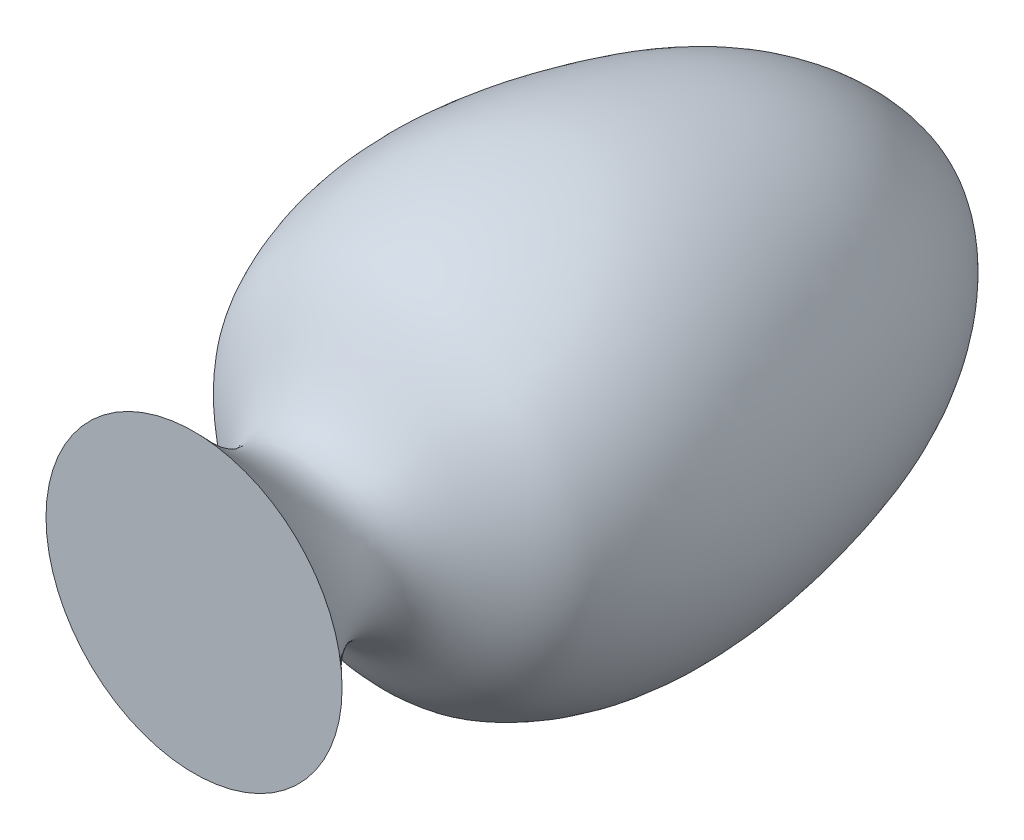
from build123d import *


with BuildPart() as part:
    # Sketch2 → Revolve4 (revolve)
    with BuildSketch(Plane(origin=(0, 0, 0), x_dir=(1, 0, 0), z_dir=(0, 1, 0))):
        with BuildLine():
            Line((200, -1000), (0, -1000))
            Line((0, -1000), (0, 0))
            add(Edge.make_bspline(
                [(0, 0), (101.557710259, -26.841383844), (214.347525711, -143.962732414), (294.480599989, -403.735703893), (311.598393321, -603.84806482), (198.797715862, -815.10136326), (-7.405534242, -810.839395017), (200, -1000)],
                knots=[0, 0, 0, 0, 0.252723118, 0.388742555, 0.70089563, 0.718239143, 1, 1, 1, 1], degree=3))
        make_face()
    revolve(axis=Axis((0, 0, 0), (0, 0, 1)))


solid = part.part
